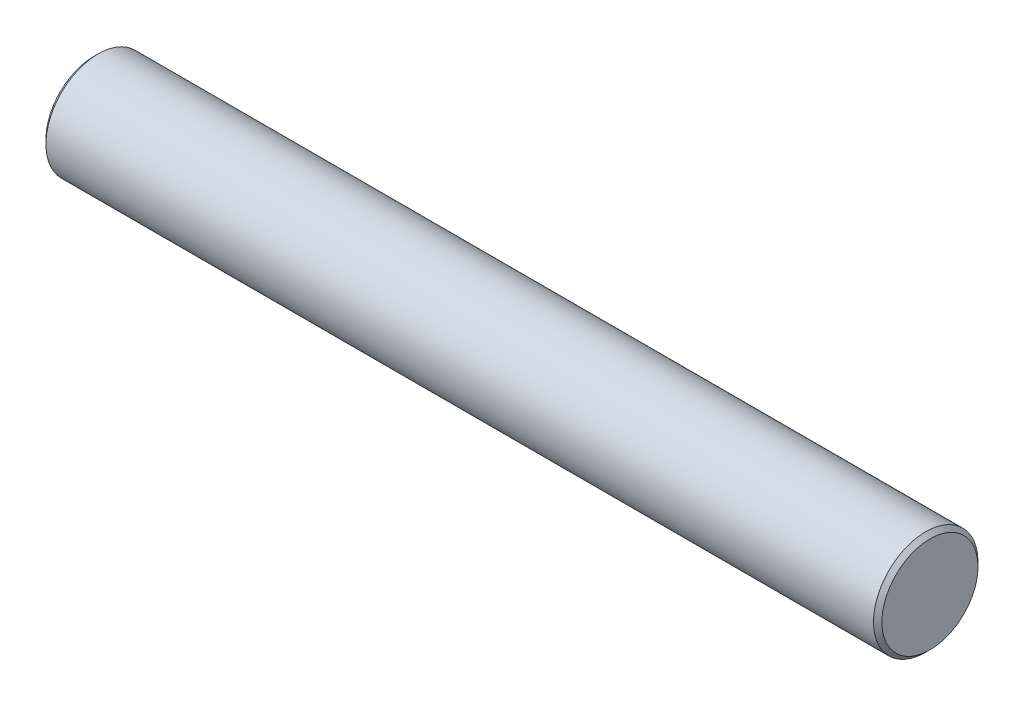
from build123d import *

# Parameters (mm, degrees)
SKETCH1_R           = 3.175
BOSS_EXTRUDE1_DEPTH = 50.8
CHAMFER1_SIZE       = 0.254


with BuildPart() as part:
    # Sketch1 → Boss-Extrude1 (new body)
    with BuildSketch(Plane(origin=(0, 0, 0), x_dir=(0, 0, -1), z_dir=(1, 0, 0))):
        Circle(SKETCH1_R)
    extrude(amount=-BOSS_EXTRUDE1_DEPTH)

    # Chamfer1
    chamfer1_edges = [part.edges().sort_by_distance(p)[0] for p in [
        (0, 0, 3.175),
        (-50.8, 0, 3.175),
    ]]
    chamfer(chamfer1_edges, length=CHAMFER1_SIZE)


solid = part.part
